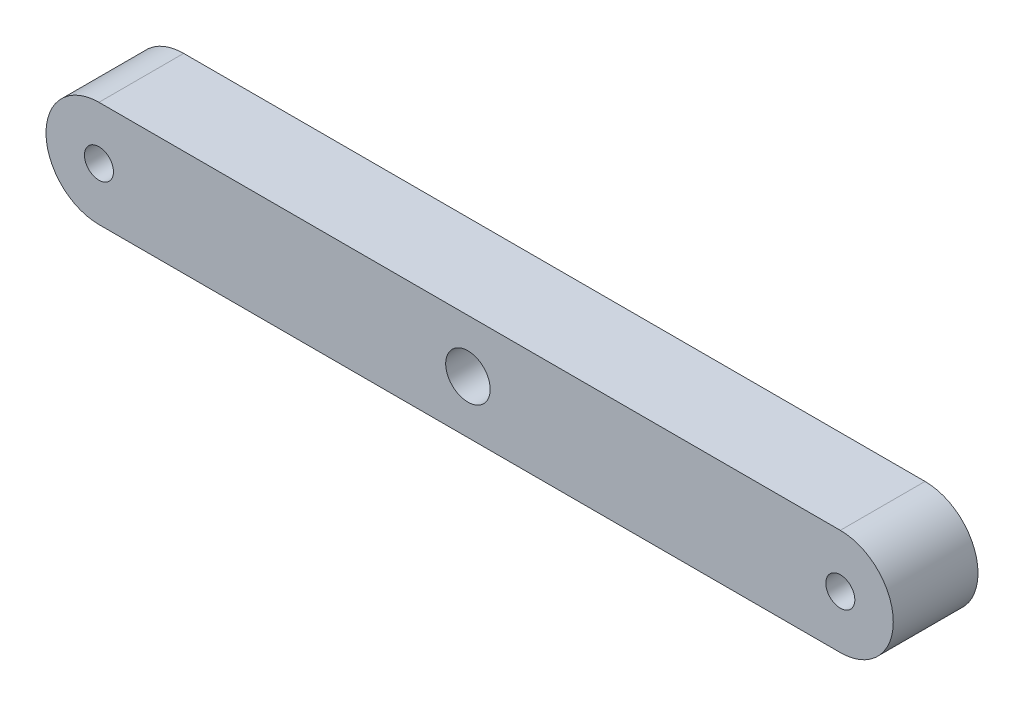
from build123d import *

# Parameters (mm, degrees)
BOSS_EXTRUDE1_DEPTH     = 10.16
CUT_EXTRUDE1_START      = -11.16
SKETCH2_R               = 1.7399
CUT_EXTRUDE1_DEPTH      = 12.16
SKETCH3_R               = 2.667
CUT_EXTRUDE2_DEPTH      = 1
CUT_EXTRUDE2_DEPTH_BACK = 11.16


with BuildPart() as part:
    # Sketch1 → Boss-Extrude1 (new body)
    with BuildSketch(Plane.XY):
        with BuildLine():
            Line((0, 6.35), (88.9, 6.35))
            ThreePointArc((88.9, 6.35), (95.25, 0), (88.9, -6.35))
            Line((88.9, -6.35), (0, -6.35))
            ThreePointArc((0, -6.35), (-6.35, 0), (0, 6.35))
        make_face()
    extrude(amount=BOSS_EXTRUDE1_DEPTH)

    # Sketch2 → Cut-Extrude1 (cut)
    with BuildSketch(Plane.XY.offset(10.16).offset(CUT_EXTRUDE1_START)):
        Circle(SKETCH2_R)
    cut_extrude1 = extrude(amount=CUT_EXTRUDE1_DEPTH, mode=Mode.SUBTRACT)

    # Mirror1: Cut-Extrude1 across plane
    add(cut_extrude1.mirror(Plane(origin=(44.45, 0, 0), x_dir=(0, 0, 1), z_dir=(1, 0, 0))), mode=Mode.SUBTRACT)

    # Sketch3 → Cut-Extrude2 (cut, two sides)
    with BuildSketch(Plane.XY.offset(10.16)) as cut_extrude2_sk:
        with Locations((44.2468, 0)):
            Circle(SKETCH3_R)
    extrude(amount=CUT_EXTRUDE2_DEPTH, mode=Mode.SUBTRACT)
    extrude(cut_extrude2_sk.sketch, amount=-CUT_EXTRUDE2_DEPTH_BACK, mode=Mode.SUBTRACT)


solid = part.part
